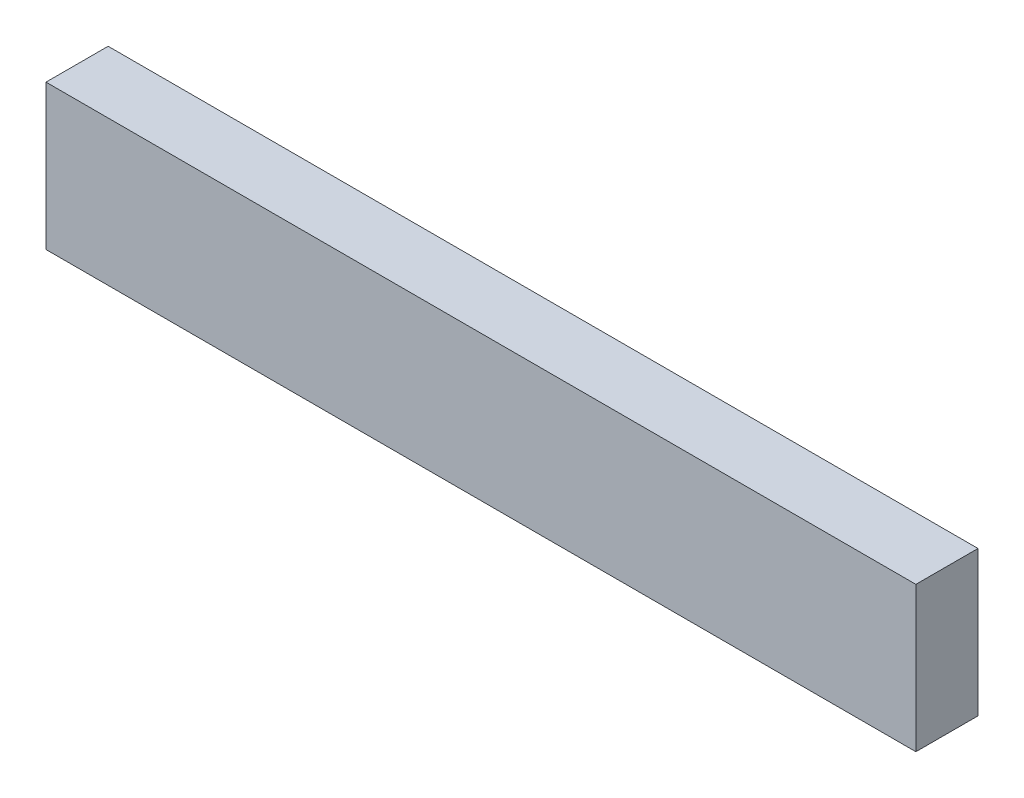
from build123d import *

# Parameters (mm, degrees)
BOSS_EXTRUDE1_DEPTH      = 266.7
BOSS_EXTRUDE1_DEPTH_BACK = 266.7
SKETCH3_W                = 38.1
SKETCH3_H                = 88.9


with BuildPart() as part:
    # Sketch3 → Boss-Extrude1 (new, two sides: drawn at the far end of the back side and taken through both)
    with BuildSketch(Plane(origin=(0, 0, 0), x_dir=(0, 0, -1), z_dir=(1, 0, 0)).offset(-BOSS_EXTRUDE1_DEPTH_BACK)):
        Rectangle(SKETCH3_W, SKETCH3_H)
    extrude(amount=BOSS_EXTRUDE1_DEPTH + BOSS_EXTRUDE1_DEPTH_BACK)


solid = part.part
